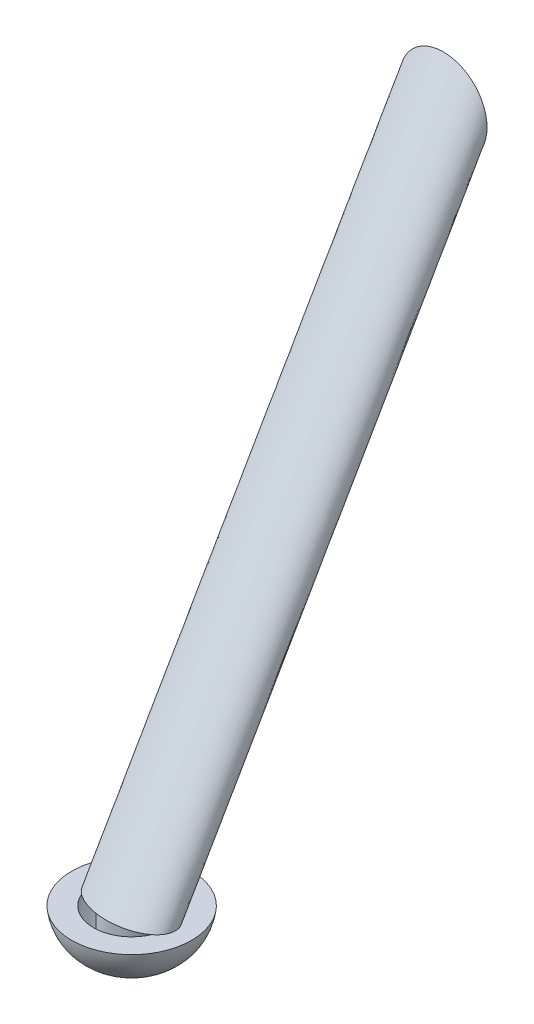
from build123d import *

# Parameters (mm, degrees)
SKETCH2_R          = 152.4
SKETCH2_R_2        = 139.7
SKETCH6_R          = 415.386019323
CUT_EXTRUDE2_DEPTH = 2357.625194534


with BuildPart() as part:
    # Sweep2: sweep along a path in Sketch1
    with BuildLine(Plane(origin=(0, 0, 0), x_dir=(0, 0, -1), z_dir=(1, 0, 0))) as sweep2_path:
        Line((0, 0), (-1175.846136566, -2036.625250417))
    # Sketch2 → Sweep2 (sweep)
    with BuildSketch(Plane.XY):
        Circle(SKETCH2_R)
        Circle(SKETCH2_R_2, mode=Mode.SUBTRACT)
    sweep(path=sweep2_path.line)

    # Sketch6 → Cut-Extrude2 (cut, through all)
    with BuildSketch(Plane(origin=(0, -1884.225250417, 0), x_dir=(1, 0, 0), z_dir=(0, 1, 0))):
        with Locations((0, -1175.846136566)):
            Circle(SKETCH6_R)
    extrude(amount=-CUT_EXTRUDE2_DEPTH, mode=Mode.SUBTRACT)

    # Sketch7 → Revolve1 (revolve)
    with BuildSketch(Plane(origin=(0, 0, 0), x_dir=(0, 0, -1), z_dir=(1, 0, 0))):
        with BuildLine():
            Line((-1220.887578802, -1884.225250417), (-1297.087578802, -1884.225250417))
            ThreePointArc((-1297.087578802, -1884.225250417), (-1225.378354687, -2005.601258808), (-1087.857955542, -2036.625250417))
            Line((-1087.857955542, -2036.625250417), (-1087.857955542, -1884.225250417))
            Line((-1087.857955542, -1884.225250417), (-1175.846136566, -1884.225250417))
            Line((-1175.846136566, -1884.225250417), (-1175.846136566, -1975.66616445))
            ThreePointArc((-1175.846136566, -1975.66616445), (-1210.663906271, -1936.002917266), (-1220.887578802, -1884.225250417))
        make_face()
    revolve(axis=Axis((0, -1884.225250417, 1087.857955542), (0, -1, 0)))


solid = part.part
